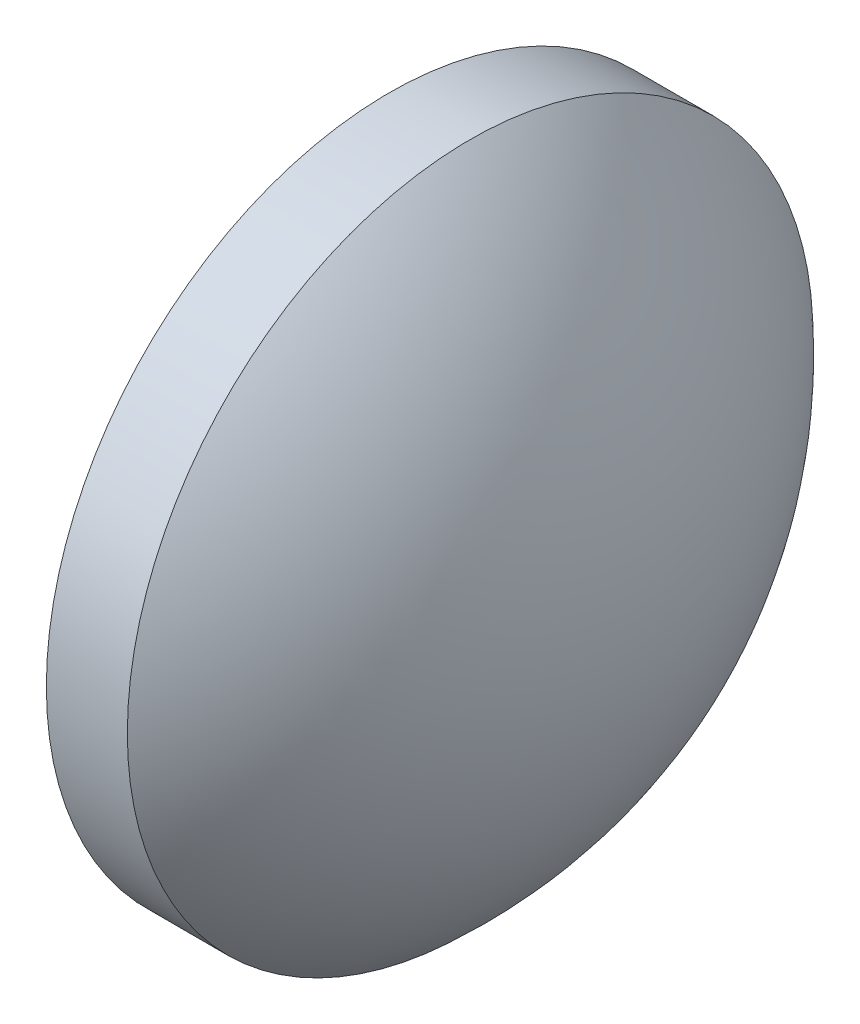
from build123d import *


with BuildPart() as part:
    # 草图1 → 旋转1 (revolve)
    with BuildSketch(Plane.XY, mode=Mode.PRIVATE) as revolve_1_sk:
        with BuildLine():
            Line((409.270535231, 28.290828784), (409.270535231, 34.640828784))
            Line((409.270535231, 34.640828784), (410.770535231, 34.640828784))
            ThreePointArc((410.770535231, 34.640828784), (412.839463223, 31.760789158), (413.570535231, 28.290828784))
            Line((413.570535231, 28.290828784), (409.270535231, 28.290828784))
        make_face()
    revolve(revolve_1_sk.sketch.rotate(Axis((407.010004085, 28.290828784, 0), (1, 0, 0)), 180), axis=Axis((407.010004085, 28.290828784, 0), (1, 0, 0)))  # turned: the seam where the file's is


solid = part.part
